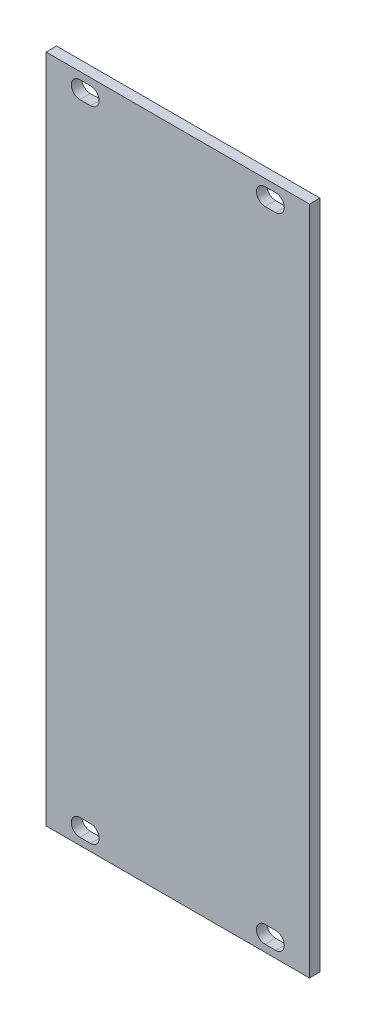
from build123d import *

# Parameters (mm, degrees)
SKETCH1_W           = 50.5
SKETCH1_H           = 128.5
BOSS_EXTRUDE1_DEPTH = 2


with BuildPart() as part:
    # Sketch1 → Boss-Extrude1 (new body)
    with BuildSketch(Plane.XY):
        Rectangle(SKETCH1_W, SKETCH1_H)
        with BuildLine():
            Line((-18.766, -59.6), (-16.734, -59.6))
            ThreePointArc((-16.734, -59.6), (-15.084, -61.25), (-16.734, -62.9))
            Line((-16.734, -62.9), (-18.766, -62.9))
            ThreePointArc((-18.766, -62.9), (-20.416, -61.25), (-18.766, -59.6))
        make_face(mode=Mode.SUBTRACT)
        with BuildLine():
            Line((-18.766, 62.9), (-16.734, 62.9))
            ThreePointArc((-16.734, 62.9), (-15.084, 61.25), (-16.734, 59.6))
            Line((-16.734, 59.6), (-18.766, 59.6))
            ThreePointArc((-18.766, 59.6), (-20.416, 61.25), (-18.766, 62.9))
        make_face(mode=Mode.SUBTRACT)
        with BuildLine():
            Line((16.734000014, 62.9), (18.766000014, 62.9))
            ThreePointArc((18.766000014, 62.9), (20.416000014, 61.25), (18.766000014, 59.6))
            Line((18.766000014, 59.6), (16.734000014, 59.6))
            ThreePointArc((16.734000014, 59.6), (15.084000014, 61.25), (16.734000014, 62.9))
        make_face(mode=Mode.SUBTRACT)
        with BuildLine():
            Line((16.734000014, -59.6), (18.766000014, -59.6))
            ThreePointArc((18.766000014, -59.6), (20.416000014, -61.25), (18.766000014, -62.9))
            Line((18.766000014, -62.9), (16.734000014, -62.9))
            ThreePointArc((16.734000014, -62.9), (15.084000014, -61.25), (16.734000014, -59.6))
        make_face(mode=Mode.SUBTRACT)
    extrude(amount=BOSS_EXTRUDE1_DEPTH)


solid = part.part
